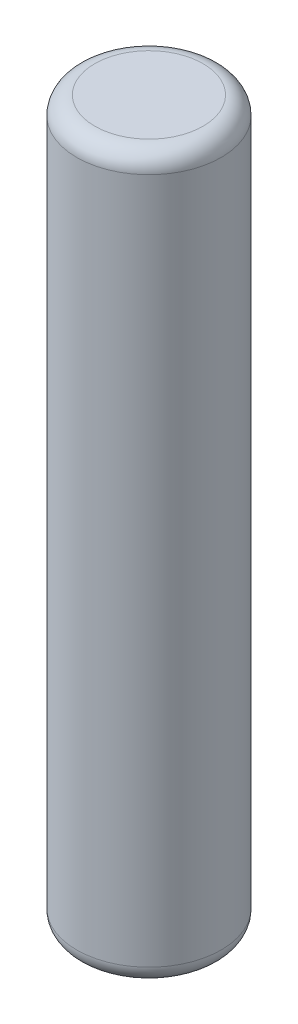
from build123d import *

# Parameters (mm, degrees)
SKETCH1_R           = 4
BOSS_EXTRUDE1_DEPTH = 40
FILLET1_R           = 1


with BuildPart() as part:
    # Sketch1 → Boss-Extrude1 (new body)
    with BuildSketch(Plane(origin=(0, 0, 0), x_dir=(1, 0, 0), z_dir=(0, 1, 0))):
        Circle(SKETCH1_R)
    extrude(amount=BOSS_EXTRUDE1_DEPTH)

    # Fillet1
    fillet1_edges = [part.edges().sort_by_distance(p)[0] for p in [
        (-4, 0, 0),
        (-4, 40, 0),
    ]]
    fillet(fillet1_edges, radius=FILLET1_R)


solid = part.part
